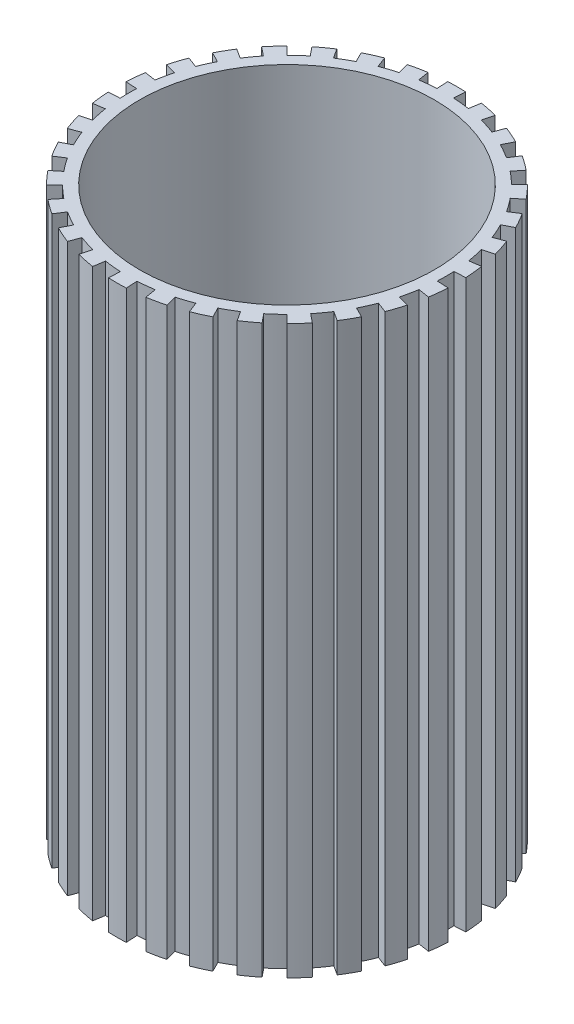
from build123d import *

# Parameters (mm, degrees)
SKETCH2_R           = 65
BOSS_EXTRUDE1_DEPTH = 250


with BuildPart() as part:
    # Sketch2 → Boss-Extrude1 (new body)
    with BuildSketch(Plane(origin=(0, 0, 0), x_dir=(1, 0, 0), z_dir=(0, 1, 0))):
        with BuildLine():
            Line((-11.012600748, 69.128305525), (-11.799215087, 74.066041634))
            ThreePointArc((-11.799215087, 74.066041634), (-15.659361787, 73.347013494), (-19.476587264, 72.426946288))
            Line((-19.476587264, 72.426946288), (-18.178148113, 67.598483202))
            ThreePointArc((-18.178148113, 67.598483202), (-21.691066852, 66.554471066), (-25.144531884, 65.32803775))
            Line((-25.144531884, 65.32803775), (-26.940569876, 69.994326161))
            ThreePointArc((-26.940569876, 69.994326161), (-30.566868752, 68.488440884), (-34.109385966, 66.79483355))
            Line((-34.109385966, 66.79483355), (-31.835426902, 62.341844647))
            ThreePointArc((-31.835426902, 62.341844647), (-35.054517609, 60.590269806), (-38.177526321, 58.672621247))
            Line((-38.177526321, 58.672621247), (-40.904492486, 62.863522765))
            ThreePointArc((-40.904492486, 62.863522765), (-44.138456878, 60.636594763), (-47.251440827, 58.243466069))
            Line((-47.251440827, 58.243466069), (-44.101344772, 54.360568332))
            ThreePointArc((-44.101344772, 54.360568332), (-46.885917737, 51.977983012), (-49.541979661, 49.452929653))
            Line((-49.541979661, 49.452929653), (-53.080692494, 52.985281771))
            ThreePointArc((-53.080692494, 52.985281771), (-55.780982638, 50.134638485), (-58.328380986, 47.146579638))
            Line((-58.328380986, 47.146579638), (-54.439822253, 44.003474329))
            ThreePointArc((-54.439822253, 44.003474329), (-56.668178276, 41.094008942), (-58.741210761, 38.071907732))
            Line((-58.741210761, 38.071907732), (-62.937011529, 40.791329713))
            ThreePointArc((-62.937011529, 40.791329713), (-64.985611789, 37.441557932), (-66.856091005, 33.989161443))
            Line((-66.856091005, 33.989161443), (-62.399018271, 31.723217347))
            ThreePointArc((-62.399018271, 31.723217347), (-63.9737675, 28.41402949), (-65.373169079, 25.026960753))
            Line((-65.373169079, 25.026960753), (-70.042681156, 26.814600807))
            ThreePointArc((-70.042681156, 26.814600807), (-71.350057871, 23.112101633), (-72.461869036, 19.346253794))
            Line((-72.461869036, 19.346253794), (-67.631077767, 18.056503541))
            ThreePointArc((-67.631077767, 18.056503541), (-68.483396104, 14.492220604), (-69.148006213, 10.888215497))
            Line((-69.148006213, 10.888215497), (-74.087149514, 11.665945176))
            ThreePointArc((-74.087149514, 11.665945176), (-74.596164047, 7.772535588), (-74.900715679, 3.857822021))
            Line((-74.900715679, 3.857822021), (-69.907334634, 3.600633886))
            ThreePointArc((-69.907334634, 3.600633886), (-69.999971679, -0.062967864), (-69.900743667, -3.726397024))
            Line((-69.900743667, -3.726397024), (-74.893653929, -3.99256824))
            ThreePointArc((-74.893653929, -3.99256824), (-74.582059903, -7.906727558), (-74.066041634, -11.799215087))
            Line((-74.066041634, -11.799215087), (-69.128305525, -11.012600748))
            ThreePointArc((-69.128305525, -11.012600748), (-68.457212594, -14.615404334), (-67.598483202, -18.178148113))
            Line((-67.598483202, -18.178148113), (-72.426946288, -19.476587264))
            ThreePointArc((-72.426946288, -19.476587264), (-71.308361856, -23.24042877), (-69.994326161, -26.940569876))
            Line((-69.994326161, -26.940569876), (-65.32803775, -25.144531884))
            ThreePointArc((-65.32803775, -25.144531884), (-63.922544825, -28.529077502), (-62.341844647, -31.835426902))
            Line((-62.341844647, -31.835426902), (-66.79483355, -34.109385966))
            ThreePointArc((-66.79483355, -34.109385966), (-64.918146221, -37.558411724), (-62.863522765, -40.904492486))
            Line((-62.863522765, -40.904492486), (-58.672621247, -38.177526321))
            ThreePointArc((-58.672621247, -38.177526321), (-56.594155112, -41.195893086), (-54.360568332, -44.101344772))
            Line((-54.360568332, -44.101344772), (-58.243466069, -47.251440827))
            ThreePointArc((-58.243466069, -47.251440827), (-55.690696084, -50.234911861), (-52.985281771, -53.080692494))
            Line((-52.985281771, -53.080692494), (-49.452929653, -49.541979661))
            ThreePointArc((-49.452929653, -49.541979661), (-46.792329252, -52.062250462), (-44.003474329, -54.439822253))
            Line((-44.003474329, -54.439822253), (-47.146579638, -58.328380986))
            ThreePointArc((-47.146579638, -58.328380986), (-44.029295295, -60.715905296), (-40.791329713, -62.937011529))
            Line((-40.791329713, -62.937011529), (-38.071907732, -58.741210761))
            ThreePointArc((-38.071907732, -58.741210761), (-34.94545407, -60.65323767), (-31.723217347, -62.399018271))
            Line((-31.723217347, -62.399018271), (-33.989161443, -66.856091005))
            ThreePointArc((-33.989161443, -66.856091005), (-30.443603025, -68.543322321), (-26.814600807, -70.042681156))
            Line((-26.814600807, -70.042681156), (-25.026960753, -65.373169079))
            ThreePointArc((-25.026960753, -65.373169079), (-21.571294857, -66.593387346), (-18.056503541, -67.631077767))
            Line((-18.056503541, -67.631077767), (-19.346253794, -72.461869036))
            ThreePointArc((-19.346253794, -72.461869036), (-15.527379218, -73.375067255), (-11.665945176, -74.087149514))
            Line((-11.665945176, -74.087149514), (-10.888215497, -69.148006213))
            ThreePointArc((-10.888215497, -69.148006213), (-7.254366549, -69.623086444), (-3.600633886, -69.907334634))
            Line((-3.600633886, -69.907334634), (-3.857822021, -74.900715679))
            ThreePointArc((-3.857822021, -74.900715679), (0.067465569, -74.999969656), (3.99256824, -74.893653929))
            Line((3.99256824, -74.893653929), (3.726397024, -69.900743667))
            ThreePointArc((3.726397024, -69.900743667), (7.379612388, -69.609922576), (11.012600748, -69.128305525))
            Line((11.012600748, -69.128305525), (11.799215087, -74.066041634))
            ThreePointArc((11.799215087, -74.066041634), (15.659361787, -73.347013494), (19.476587264, -72.426946288))
            Line((19.476587264, -72.426946288), (18.178148113, -67.598483202))
            ThreePointArc((18.178148113, -67.598483202), (21.691066852, -66.554471066), (25.144531884, -65.32803775))
            Line((25.144531884, -65.32803775), (26.940569876, -69.994326161))
            ThreePointArc((26.940569876, -69.994326161), (30.566868752, -68.488440884), (34.109385966, -66.79483355))
            Line((34.109385966, -66.79483355), (31.835426902, -62.341844647))
            ThreePointArc((31.835426902, -62.341844647), (35.054517609, -60.590269806), (38.177526321, -58.672621247))
            Line((38.177526321, -58.672621247), (40.904492486, -62.863522765))
            ThreePointArc((40.904492486, -62.863522765), (44.138456878, -60.636594763), (47.251440827, -58.243466069))
            Line((47.251440827, -58.243466069), (44.101344772, -54.360568332))
            ThreePointArc((44.101344772, -54.360568332), (46.885917737, -51.977983012), (49.541979661, -49.452929653))
            Line((49.541979661, -49.452929653), (53.080692494, -52.985281771))
            ThreePointArc((53.080692494, -52.985281771), (55.780982638, -50.134638485), (58.328380986, -47.146579638))
            Line((58.328380986, -47.146579638), (54.439822253, -44.003474329))
            ThreePointArc((54.439822253, -44.003474329), (56.668178276, -41.094008942), (58.741210761, -38.071907732))
            Line((58.741210761, -38.071907732), (62.937011529, -40.791329713))
            ThreePointArc((62.937011529, -40.791329713), (64.985611789, -37.441557932), (66.856091005, -33.989161443))
            Line((66.856091005, -33.989161443), (62.399018271, -31.723217347))
            ThreePointArc((62.399018271, -31.723217347), (63.9737675, -28.41402949), (65.373169079, -25.026960753))
            Line((65.373169079, -25.026960753), (70.042681156, -26.814600807))
            ThreePointArc((70.042681156, -26.814600807), (71.350057871, -23.112101633), (72.461869036, -19.346253794))
            Line((72.461869036, -19.346253794), (67.631077767, -18.056503541))
            ThreePointArc((67.631077767, -18.056503541), (68.483396104, -14.492220604), (69.148006213, -10.888215497))
            Line((69.148006213, -10.888215497), (74.087149514, -11.665945176))
            ThreePointArc((74.087149514, -11.665945176), (74.596164047, -7.772535588), (74.900715679, -3.857822021))
            Line((74.900715679, -3.857822021), (69.907334634, -3.600633886))
            ThreePointArc((69.907334634, -3.600633886), (69.999971679, 0.062967864), (69.900743667, 3.726397024))
            Line((69.900743667, 3.726397024), (74.893653929, 3.99256824))
            ThreePointArc((74.893653929, 3.99256824), (74.582059903, 7.906727558), (74.066041634, 11.799215087))
            Line((74.066041634, 11.799215087), (69.128305525, 11.012600748))
            ThreePointArc((69.128305525, 11.012600748), (68.457212594, 14.615404334), (67.598483202, 18.178148113))
            Line((67.598483202, 18.178148113), (72.426946288, 19.476587264))
            ThreePointArc((72.426946288, 19.476587264), (71.308361856, 23.24042877), (69.994326161, 26.940569876))
            Line((69.994326161, 26.940569876), (65.32803775, 25.144531884))
            ThreePointArc((65.32803775, 25.144531884), (63.922544825, 28.529077502), (62.341844647, 31.835426902))
            Line((62.341844647, 31.835426902), (66.79483355, 34.109385966))
            ThreePointArc((66.79483355, 34.109385966), (64.918146221, 37.558411724), (62.863522765, 40.904492486))
            Line((62.863522765, 40.904492486), (58.672621247, 38.177526321))
            ThreePointArc((58.672621247, 38.177526321), (56.594155112, 41.195893086), (54.360568332, 44.101344772))
            Line((54.360568332, 44.101344772), (58.243466069, 47.251440827))
            ThreePointArc((58.243466069, 47.251440827), (55.690696084, 50.234911861), (52.985281771, 53.080692494))
            Line((52.985281771, 53.080692494), (49.452929653, 49.541979661))
            ThreePointArc((49.452929653, 49.541979661), (46.792329252, 52.062250462), (44.003474329, 54.439822253))
            Line((44.003474329, 54.439822253), (47.146579638, 58.328380986))
            ThreePointArc((47.146579638, 58.328380986), (44.029295295, 60.715905296), (40.791329713, 62.937011529))
            Line((40.791329713, 62.937011529), (38.071907732, 58.741210761))
            ThreePointArc((38.071907732, 58.741210761), (34.94545407, 60.65323767), (31.723217347, 62.399018271))
            Line((31.723217347, 62.399018271), (33.989161443, 66.856091005))
            ThreePointArc((33.989161443, 66.856091005), (30.443603025, 68.543322321), (26.814600807, 70.042681156))
            Line((26.814600807, 70.042681156), (25.026960753, 65.373169079))
            ThreePointArc((25.026960753, 65.373169079), (21.571294857, 66.593387346), (18.056503541, 67.631077767))
            Line((18.056503541, 67.631077767), (19.346253794, 72.461869036))
            ThreePointArc((19.346253794, 72.461869036), (15.527379218, 73.375067255), (11.665945176, 74.087149514))
            Line((11.665945176, 74.087149514), (10.888215497, 69.148006213))
            ThreePointArc((10.888215497, 69.148006213), (7.254366549, 69.623086444), (3.600633886, 69.907334634))
            Line((3.600633886, 69.907334634), (3.857822021, 74.900715679))
            ThreePointArc((3.857822021, 74.900715679), (-0.067465569, 74.999969656), (-3.99256824, 74.893653929))
            Line((-3.99256824, 74.893653929), (-3.726397024, 69.900743667))
            ThreePointArc((-3.726397024, 69.900743667), (-7.379612388, 69.609922576), (-11.012600748, 69.128305525))
        make_face()
        Circle(SKETCH2_R, mode=Mode.SUBTRACT)
    extrude(amount=BOSS_EXTRUDE1_DEPTH)


solid = part.part
